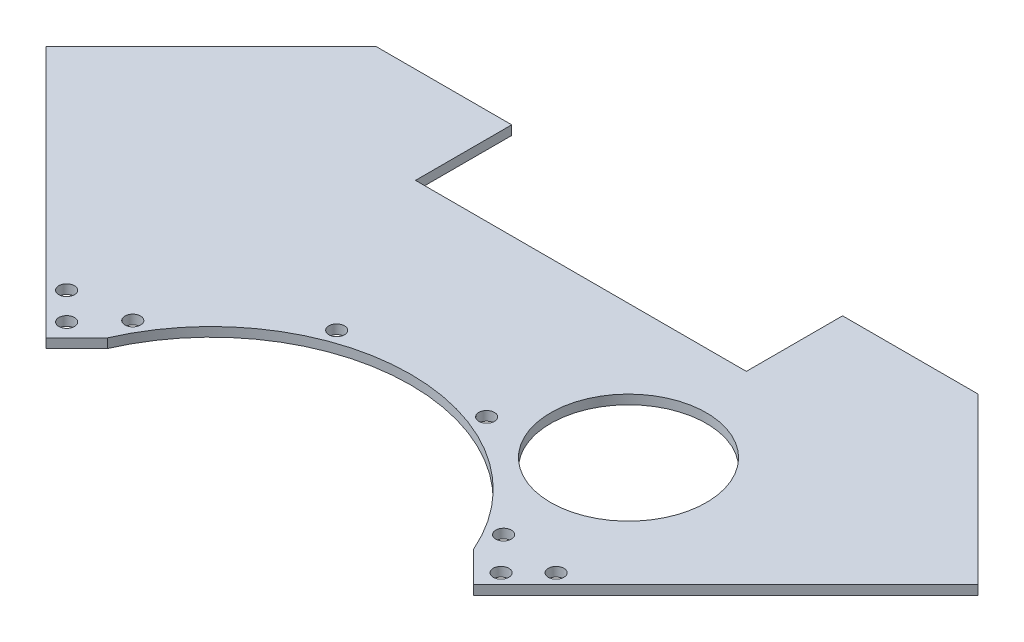
from build123d import *

# Parameters (mm, degrees)
BOSS_EXTRUDE1_DEPTH = 1.5113
SKETCH4_R           = 2.5527
CUT_EXTRUDE1_DEPTH  = 4.0226
CUT_EXTRUDE4_DEPTH  = 4.0226
SKETCH7_R           = 2.5527
CUT_EXTRUDE2_DEPTH  = 4.0226
SKETCH8_R           = 25.4
CUT_EXTRUDE3_DEPTH  = 4.0226


with BuildPart() as part:
    # Sketch3 → Boss-Extrude1 (new body, symmetric)
    with BuildSketch(Plane(origin=(0, 0, 0), x_dir=(1, 0, 0), z_dir=(0, 1, 0))):
        with BuildLine():
            Line((64.255461557, 10.37392483), (152.047852166, 98.16631544))
            Line((152.047852166, 98.16631544), (98.16631544, 152.047852166))
            Line((98.16631544, 152.047852166), (53.975, 152.047852166))
            Line((53.975, 152.047852166), (53.975, 120.65))
            Line((53.975, 120.65), (-53.975, 120.65))
            Line((-53.975, 120.65), (-53.975, 152.047852166))
            Line((-53.975, 152.047852166), (-98.16631544, 152.047852166))
            Line((-98.16631544, 152.047852166), (-152.047852166, 98.16631544))
            Line((-152.047852166, 98.16631544), (-64.255461557, 10.37392483))
            ThreePointArc((-64.255461557, 10.37392483), (0, 65.0875), (64.255461557, 10.37392483))
        make_face()
    extrude(amount=BOSS_EXTRUDE1_DEPTH, both=True)

    # Sketch4 → Cut-Extrude1 (cut, through all)
    with BuildSketch(Plane(origin=(0, 1.5113, 0), x_dir=(1, 0, 0), z_dir=(0, 1, 0))):
        with Locations((24.461985581, 65.426552419)):
            Circle(SKETCH4_R)
        with Locations((60.491874454, 34.925)):
            Circle(SKETCH4_R)
        with Locations((-60.491874454, 34.925)):
            Circle(SKETCH4_R)
        with Locations((-24.461985581, 65.426552419)):
            Circle(SKETCH4_R)
    extrude(amount=-CUT_EXTRUDE1_DEPTH, mode=Mode.SUBTRACT)

    # Sketch6 → Cut-Extrude4 (cut, through all)
    with BuildSketch(Plane(origin=(0, 1.5113, 0), x_dir=(1, 0, 0), z_dir=(0, 1, 0))):
        Polygon((69.743195158, 15.861658432), (60.762939037, 24.841914553), (59.718206073, 25.886647517), (64.255461557, 10.37392483), align=None)
    cut_extrude4 = extrude(amount=-CUT_EXTRUDE4_DEPTH, mode=Mode.SUBTRACT)

    # Sketch7 → Cut-Extrude2 (cut, through all)
    with BuildSketch(Plane(origin=(0, 1.5113, 0), x_dir=(1, 0, 0), z_dir=(0, 1, 0))):
        with Locations((70.865727173, 23.719382538)):
            Circle(SKETCH7_R)
        with Locations((79.845983295, 32.699638659)):
            Circle(SKETCH7_R)
    cut_extrude2 = extrude(amount=-CUT_EXTRUDE2_DEPTH, mode=Mode.SUBTRACT)

    # Mirror1: Cut-Extrude4, Cut-Extrude2 across plane
    add(cut_extrude4.mirror(Plane(origin=(0, 0, 0), x_dir=(0, 0, 1), z_dir=(1, 0, 0))), mode=Mode.SUBTRACT)
    add(cut_extrude2.mirror(Plane(origin=(0, 0, 0), x_dir=(0, 0, 1), z_dir=(1, 0, 0))), mode=Mode.SUBTRACT)

    # Sketch8 → Cut-Extrude3 (cut, through all)
    with BuildSketch(Plane(origin=(0, 1.5113, 0), x_dir=(1, 0, 0), z_dir=(0, 1, 0))):
        with Locations((59.128754095, 77.058092601)):
            Circle(SKETCH8_R)
    extrude(amount=-CUT_EXTRUDE3_DEPTH, mode=Mode.SUBTRACT)


solid = part.part
